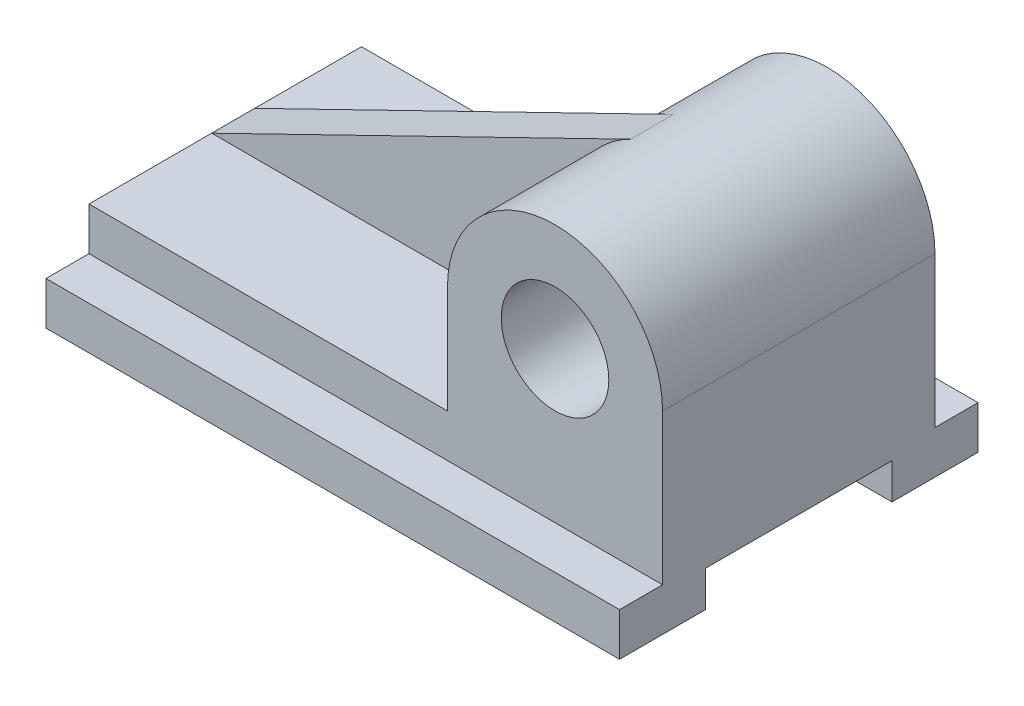
from build123d import *

# Parameters (mm, degrees)
BOSS_EXTRUDE1_DEPTH = 160
SKETCH3_R           = 15
BOSS_EXTRUDE2_DEPTH = 76
BOSS_EXTRUDE4_DEPTH = 12


with BuildPart() as part:
    # Sketch2 → Boss-Extrude1 (new body)
    with BuildSketch(Plane(origin=(0, 0, 0), x_dir=(0, 0, -1), z_dir=(1, 0, 0))):
        Polygon((53.777777778, 0), (53.777777778, 12), (41.777777778, 12), (41.777777778, 24), (-34.222222222, 24), (-34.222222222, 12), (-46.222222222, 12), (-46.222222222, 0), (-22.222222222, 0), (-22.222222222, 10), (29.777777778, 10), (29.777777778, 0), align=None)
    extrude(amount=BOSS_EXTRUDE1_DEPTH)

    # Sketch3 → Boss-Extrude2 (add)
    with BuildSketch(Plane.XY.offset(34.222222222)):
        with BuildLine():
            Line((100, 24), (160, 24))
            Line((160, 24), (160, 54))
            ThreePointArc((160, 54), (130, 84), (100, 54))
            Line((100, 54), (100, 24))
        make_face()
        with Locations((130, 54)):
            Circle(SKETCH3_R, mode=Mode.SUBTRACT)
    extrude(amount=-BOSS_EXTRUDE2_DEPTH)

    # Sketch4 → Boss-Extrude4 (add)
    with BuildSketch(Plane.XY):
        with BuildLine():
            Line((116.853932584, 80.966292135), (0, 24))
            Line((0, 24), (100, 24))
            Line((100, 24), (100, 54))
            ThreePointArc((100, 54), (104.56005088, 69.8999682), (116.853932584, 80.966292135))
        make_face()
    extrude(amount=-BOSS_EXTRUDE4_DEPTH)


solid = part.part
